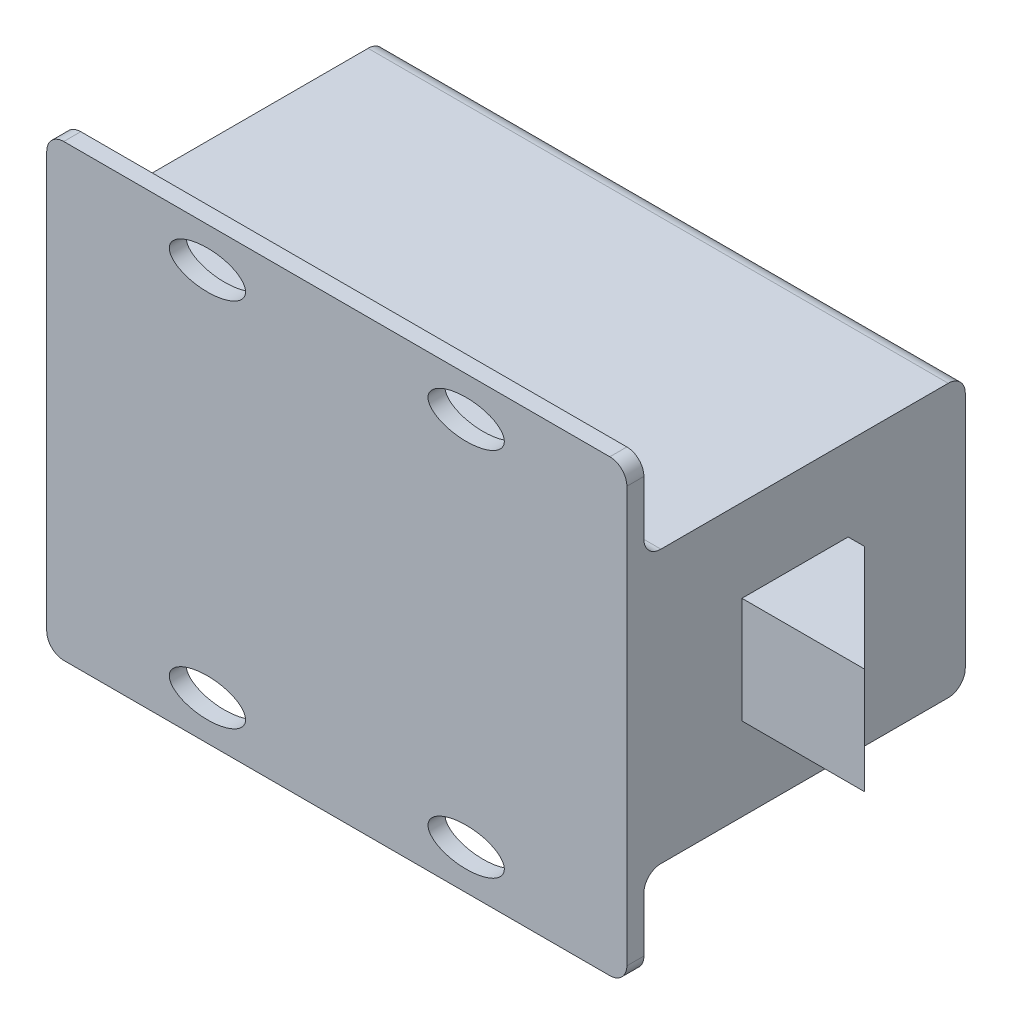
from build123d import *

# Parameters (mm, degrees)
SKETCH1_W           = 54.102
SKETCH1_H           = 41.91
BOSS_EXTRUDE1_DEPTH = 1.5875
FILLET1_R           = 1.5875
SKETCH2_W           = 54.102
SKETCH2_H           = 25.4
BOSS_EXTRUDE2_DEPTH = 29.972
FILLET2_R           = 1.5875
FILLET3_R           = 1.5875
SKETCH3_RX          = 3.556
SKETCH3_RY          = 1.778
CUT_EXTRUDE1_DEPTH  = 2.5875
SKETCH4_W           = 9.906
SKETCH4_H           = 9.906
BOSS_EXTRUDE3_DEPTH = 11.43
CUT_EXTRUDE2_DEPTH  = 26.9080001


with BuildPart() as part:
    # Sketch1 → Boss-Extrude1 (new body)
    with BuildSketch(Plane.XY):
        Rectangle(SKETCH1_W, SKETCH1_H)
    extrude(amount=BOSS_EXTRUDE1_DEPTH)

    # Fillet1
    fillet1_edges = [part.edges().sort_by_distance(p)[0] for p in [
        (27.051, -20.955, 0.79375),
        (-27.051, -20.955, 0.79375),
        (-27.051, 20.955, 0.79375),
        (27.051, 20.955, 0.79375),
    ]]
    fillet(fillet1_edges, radius=FILLET1_R)

    # Sketch2 → Boss-Extrude2 (add)
    with BuildSketch(Plane(origin=(0, 0, 0), x_dir=(-1, 0, 0), z_dir=(0, 0, -1))):
        Rectangle(SKETCH2_W, SKETCH2_H)
    extrude(amount=BOSS_EXTRUDE2_DEPTH)

    # Fillet2
    fillet2_edges = [part.edges().sort_by_distance(p)[0] for p in [
        (0, 12.7, 0),
        (0, -12.7, 0),
    ]]
    fillet(fillet2_edges, radius=FILLET2_R)

    # Fillet3
    fillet3_edges = [part.edges().sort_by_distance(p)[0] for p in [
        (0, 12.7, -29.972),
        (0, -12.7, -29.972),
    ]]
    fillet(fillet3_edges, radius=FILLET3_R)

    # Sketch3 → Cut-Extrude1 (cut, through all)
    with BuildSketch(Plane(origin=(0, 0, 0), x_dir=(-1, 0, 0), z_dir=(0, 0, -1))):
        with Locations(Location((-12.065, -17.274273354), (0, 0, 180))):
            Ellipse(SKETCH3_RX, SKETCH3_RY)
        with Locations((12.065, -17.274273354)):
            Ellipse(SKETCH3_RX, SKETCH3_RY)
        with Locations((12.065, 17.274273354)):
            Ellipse(SKETCH3_RX, SKETCH3_RY)
        with Locations(Location((-12.065, 17.274273354), (0, 0, 180))):
            Ellipse(SKETCH3_RX, SKETCH3_RY)
    extrude(amount=-CUT_EXTRUDE1_DEPTH, mode=Mode.SUBTRACT)

    # Sketch4 → Boss-Extrude3 (add)
    with BuildSketch(Plane(origin=(27.051, 0, 0), x_dir=(0, 0, -1), z_dir=(1, 0, 0))):
        with Locations((14.097, 0)):
            Rectangle(SKETCH4_W, SKETCH4_H)
    extrude(amount=BOSS_EXTRUDE3_DEPTH)

    # Sketch6 → Cut-Extrude2 (cut, through all)
    with BuildSketch(Plane(origin=(0, 4.953, 0), x_dir=(1, 0, 0), z_dir=(0, 1, 0))):
        Polygon((38.481, 9.144), (28.575, 19.05), (38.481, 19.05), align=None)
    extrude(amount=-CUT_EXTRUDE2_DEPTH, mode=Mode.SUBTRACT)


solid = part.part
